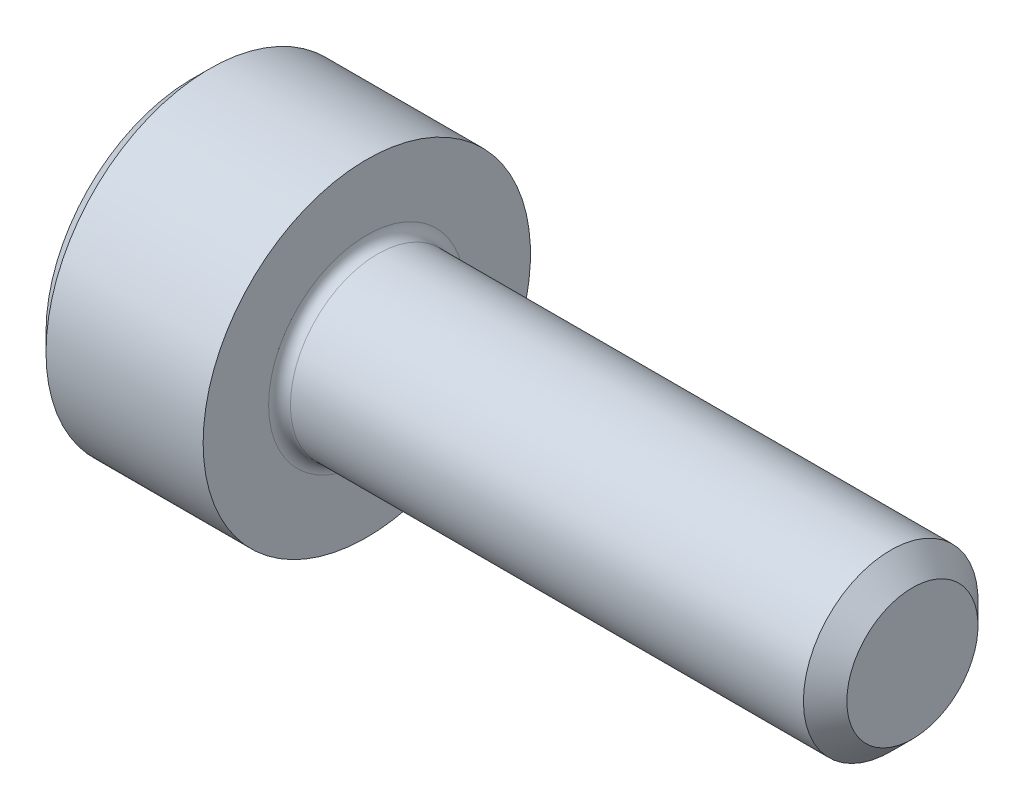
from build123d import *

# Parameters (mm, degrees)
FILLET1_R   = 0.1
HEX_2_DEPTH = 0.7


with BuildPart() as part:
    # BodySke → Base-Revolve (revolve)
    with BuildSketch(Plane.XY):
        Polygon((0, 0), (0, 1.34), (0.16, 1.5), (1.6, 1.5), (1.6, 0.8), (6.401, 0.8), (6.6, 0.601), (6.6, 0), align=None)
    revolve(axis=Axis((-31.75, 0, 0), (1, 0, 0)))

    # Fillet1
    fillet1_edges = [part.edges().sort_by_distance(p)[0] for p in [
        (1.6, -0.8, 0),
    ]]
    fillet(fillet1_edges, radius=FILLET1_R)

    # Sketch2 → Hex-PreBroach (revolve, cut)
    with BuildSketch(Plane.XY):
        Polygon((0, 0.7725), (0.7, 0.7725), (1.146003083, 0), (0, 0), align=None)
    revolve(axis=Axis((0, 0, 0), (1, 0, 0)), mode=Mode.SUBTRACT)

    # Sketch3 → Hex 2 (cut)
    with BuildSketch(Plane(origin=(0, 0, 0), x_dir=(0, 0.5, 0.866025404), z_dir=(-1, 0, 0))):
        Polygon((0.446003083, 0.7725), (-0.446003083, 0.7725), (-0.892006166, 0), (-0.446003083, -0.7725), (0.446003083, -0.7725), (0.892006166, 0), align=None)
    extrude(amount=-HEX_2_DEPTH, mode=Mode.SUBTRACT)


solid = part.part
